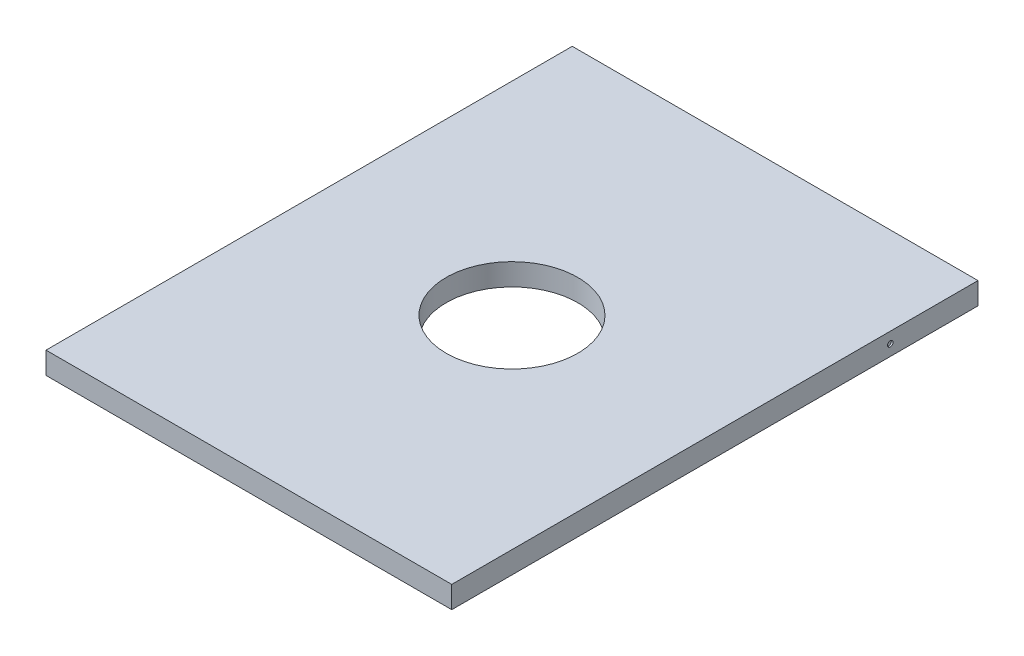
from build123d import *

# Parameters (mm, degrees)
SKETCH1_W           = 117.5004
SKETCH1_H           = 152.4
SKETCH1_R           = 19.05
BOSS_EXTRUDE1_DEPTH = 6.35
SKETCH3_R           = 0.7874
CUT_EXTRUDE1_DEPTH  = 0.508
SKETCH4_R           = 0.7874
CUT_EXTRUDE2_DEPTH  = 0.508
SKETCH5_R           = 1.7272
CUT_EXTRUDE3_DEPTH  = 6.35


with BuildPart() as part:
    # Sketch1 → Boss-Extrude1 (new body)
    with BuildSketch(Plane(origin=(0, 0, 0), x_dir=(1, 0, 0), z_dir=(0, 1, 0))):
        Rectangle(SKETCH1_W, SKETCH1_H)
        Circle(SKETCH1_R, mode=Mode.SUBTRACT)
    extrude(amount=BOSS_EXTRUDE1_DEPTH)

    # Sketch3 → Cut-Extrude1 (cut)
    with BuildSketch(Plane.ZY.offset(58.7502)):
        with Locations((-50.8, 3.175)):
            Circle(SKETCH3_R)
    extrude(amount=-CUT_EXTRUDE1_DEPTH, mode=Mode.SUBTRACT)

    # Sketch4 → Cut-Extrude2 (cut)
    with BuildSketch(Plane(origin=(58.7502, 0, 0), x_dir=(0, 0, -1), z_dir=(1, 0, 0))):
        with Locations((50.8, 3.175)):
            Circle(SKETCH4_R)
    extrude(amount=-CUT_EXTRUDE2_DEPTH, mode=Mode.SUBTRACT)

    # Sketch5 → Cut-Extrude3 (cut)
    with BuildSketch(Plane(origin=(0, 0, -76.2), x_dir=(-1, 0, 0), z_dir=(0, 0, -1))):
        with Locations((0, 3.175)):
            Circle(SKETCH5_R)
    extrude(amount=-CUT_EXTRUDE3_DEPTH, mode=Mode.SUBTRACT)


solid = part.part
